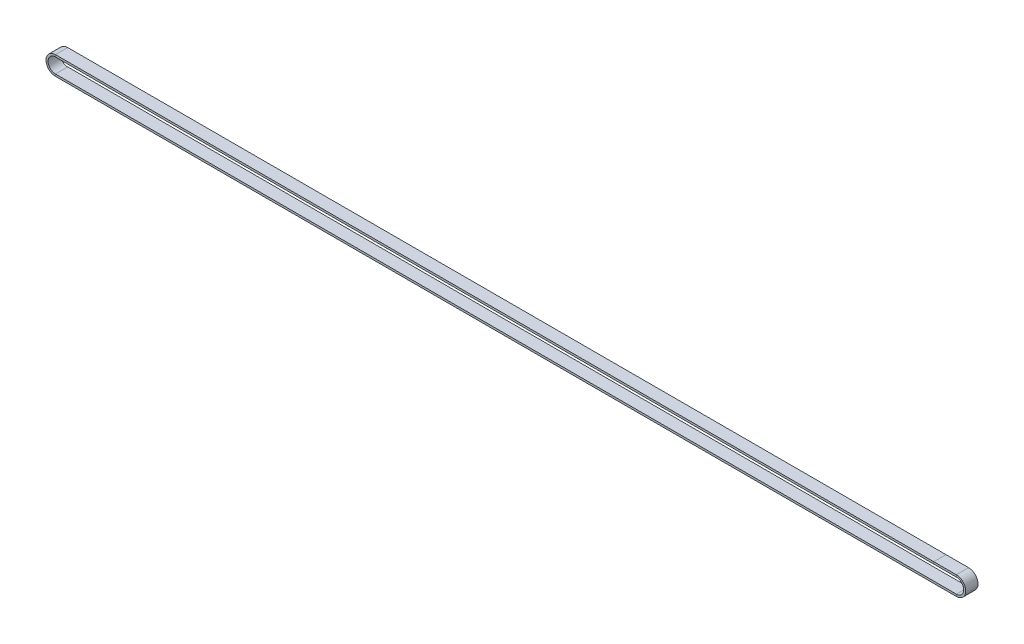
from build123d import *

# Parameters (mm, degrees)
SKETCH3_W = 9
SKETCH3_H = 1.5


with BuildPart() as part:
    # Sweep1: sweep along a path in Sketch2
    with BuildLine(Plane.XY) as sweep1_path:
        Line((0.6, -6.9), (-660.332653819, -6.9))
        ThreePointArc((-660.332653819, -6.9), (-667.232653819, 0), (-660.332653819, 6.9))
        Line((-660.332653819, 6.9), (0.6, 6.9))
        ThreePointArc((0.6, 6.9), (7.5, 0), (0.6, -6.9))
    # Sketch3 → Sweep1 (sweep)
    with BuildSketch(Plane(origin=(-16, 0, 0), x_dir=(0, 0, -1), z_dir=(1, 0, 0))):
        with Locations((-4.5, 6.15)):
            Rectangle(SKETCH3_W, SKETCH3_H)
    sweep(path=sweep1_path.line)


solid = part.part
